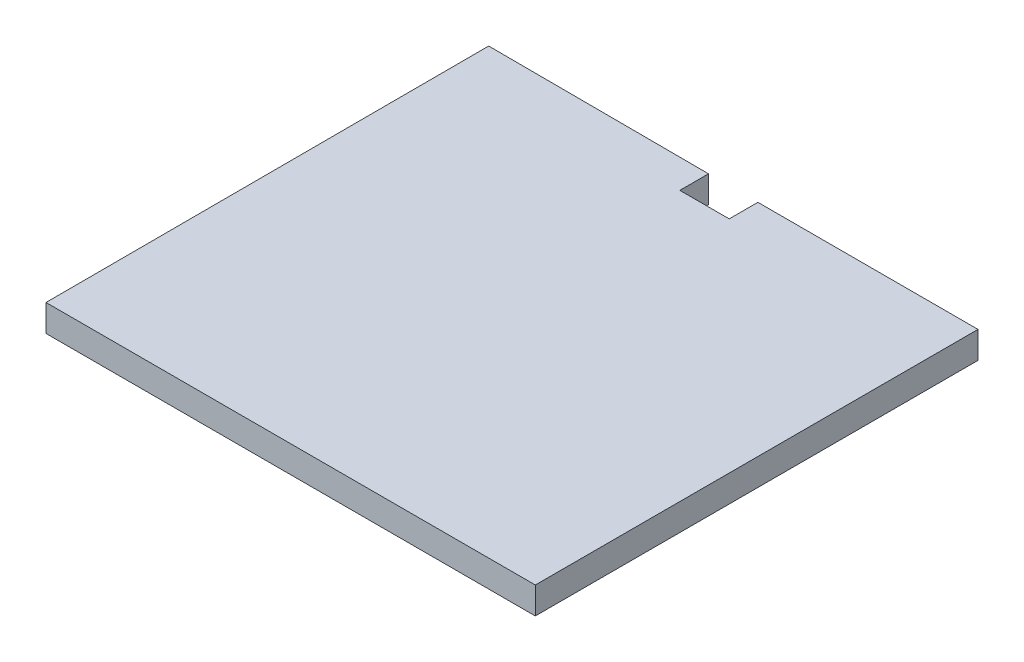
from build123d import *

# Parameters (mm, degrees)
BOSS_EXTRUDE1_DEPTH = 11.811


with BuildPart() as part:
    # Sketch2 → Boss-Extrude1 (new body)
    with BuildSketch(Plane(origin=(0, 92.076361751, 0), x_dir=(1, 0, 0), z_dir=(0, 1, 0))):
        Polygon((-11.213428319, -6.8261037), (-11.213428319, 5.786849537), (-108.204482014, 6.120182871), (-107.871148681, -188.879817129), (107.295517986, -188.879817129), (107.295517986, 5.786849537), (10.504779391, 5.786849537), (10.504779391, -6.8261037), align=None)
    extrude(amount=BOSS_EXTRUDE1_DEPTH)


solid = part.part
